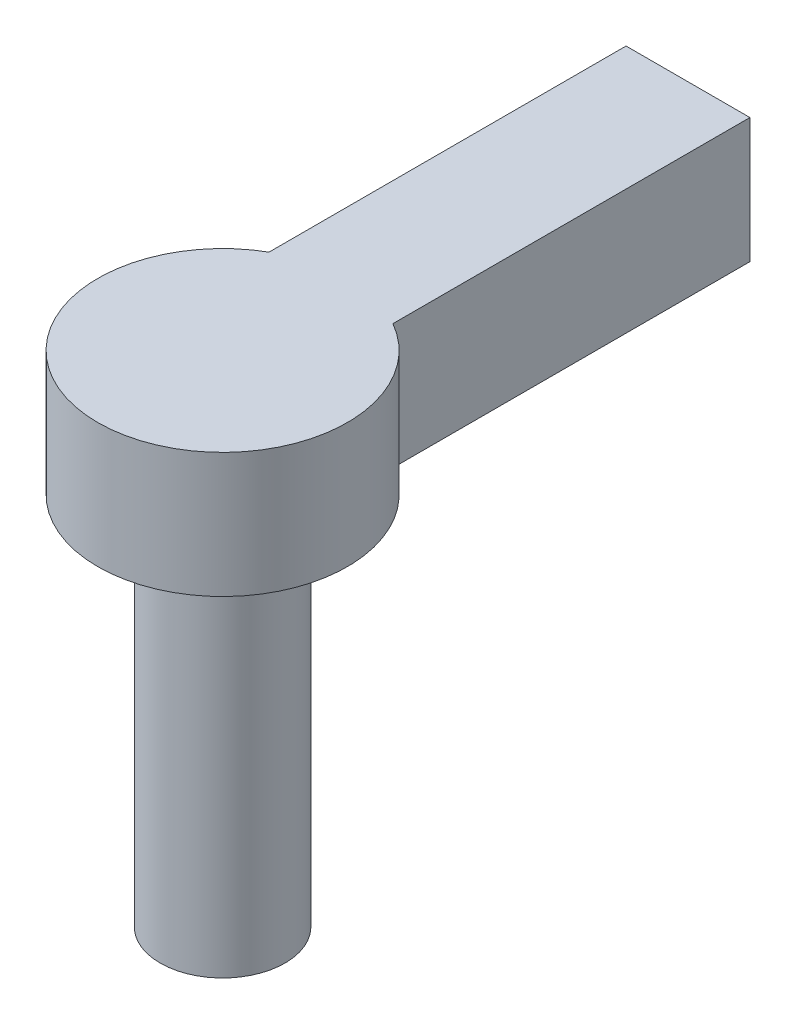
from build123d import *

# Parameters (mm, degrees)
SKETCH1_R           = 3.175
BOSS_EXTRUDE1_DEPTH = 19.05
BOSS_EXTRUDE2_DEPTH = 6.35
SKETCH4_W           = 6.30056433
SKETCH4_H           = 6.35
BOSS_EXTRUDE3_DEPTH = 14.986


with BuildPart() as part:
    # Sketch1 → Boss-Extrude1 (new body)
    with BuildSketch(Plane(origin=(0, 0, 0), x_dir=(1, 0, 0), z_dir=(0, 1, 0))):
        Circle(SKETCH1_R)
    extrude(amount=BOSS_EXTRUDE1_DEPTH)

    # Sketch3 → Boss-Extrude2 (add)
    with BuildSketch(Plane(origin=(0, 19.05, 0), x_dir=(1, 0, 0), z_dir=(0, 1, 0))):
        with BuildLine():
            Line((3.150282165, 5.513458287), (3.150282165, 8.686029988))
            Line((3.150282165, 8.686029988), (-3.150282165, 8.686029988))
            Line((-3.150282165, 8.686029988), (-3.150282165, 5.513458287))
            ThreePointArc((-3.150282165, 5.513458287), (0, -6.35), (3.150282165, 5.513458287))
        make_face()
    extrude(amount=BOSS_EXTRUDE2_DEPTH)

    # Sketch4 → Boss-Extrude3 (add)
    with BuildSketch(Plane(origin=(0, 0, -8.686029988), x_dir=(-1, 0, 0), z_dir=(0, 0, -1))):
        with Locations((0, 22.225)):
            Rectangle(SKETCH4_W, SKETCH4_H)
    extrude(amount=BOSS_EXTRUDE3_DEPTH)


solid = part.part
